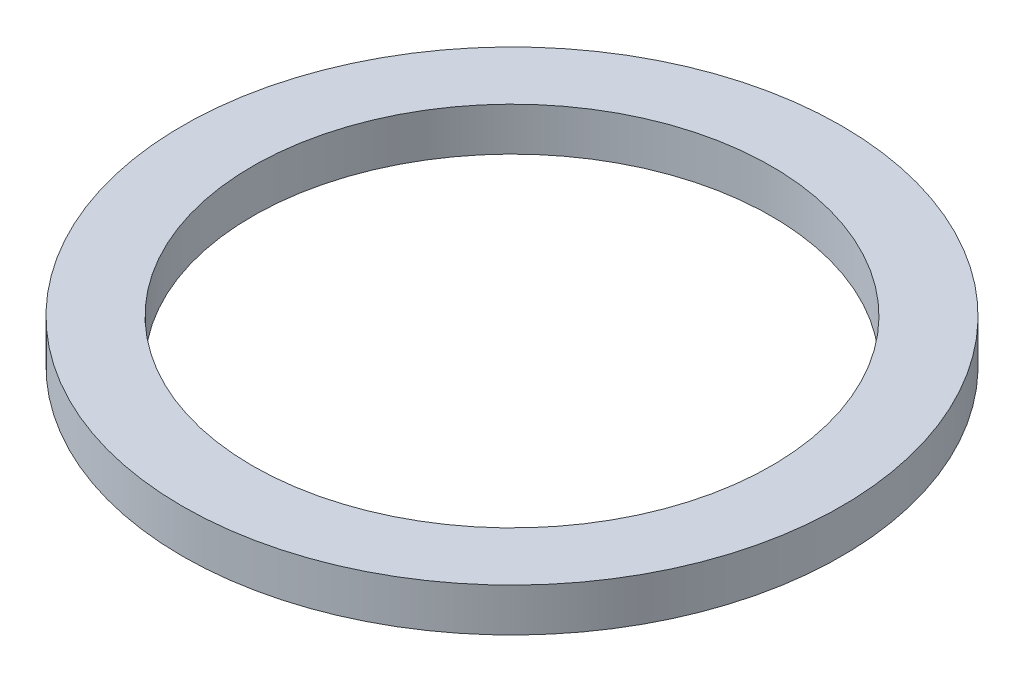
from build123d import *

# Parameters (mm, degrees)
SKETCH_1_W = 4.05
SKETCH_1_H = 2.5


with BuildPart() as part:
    # 草图1 → 旋转1 (revolve)
    with BuildSketch(Plane.XY, mode=Mode.PRIVATE) as revolve_1_sk:
        with Locations((17.025, 1.25)):
            Rectangle(SKETCH_1_W, SKETCH_1_H)
    revolve(revolve_1_sk.sketch.rotate(Axis((0, 77.144142266, 0), (0, -1, 0)), 90), axis=Axis((0, 77.144142266, 0), (0, -1, 0)))  # turned: the seam where the file's is


solid = part.part
